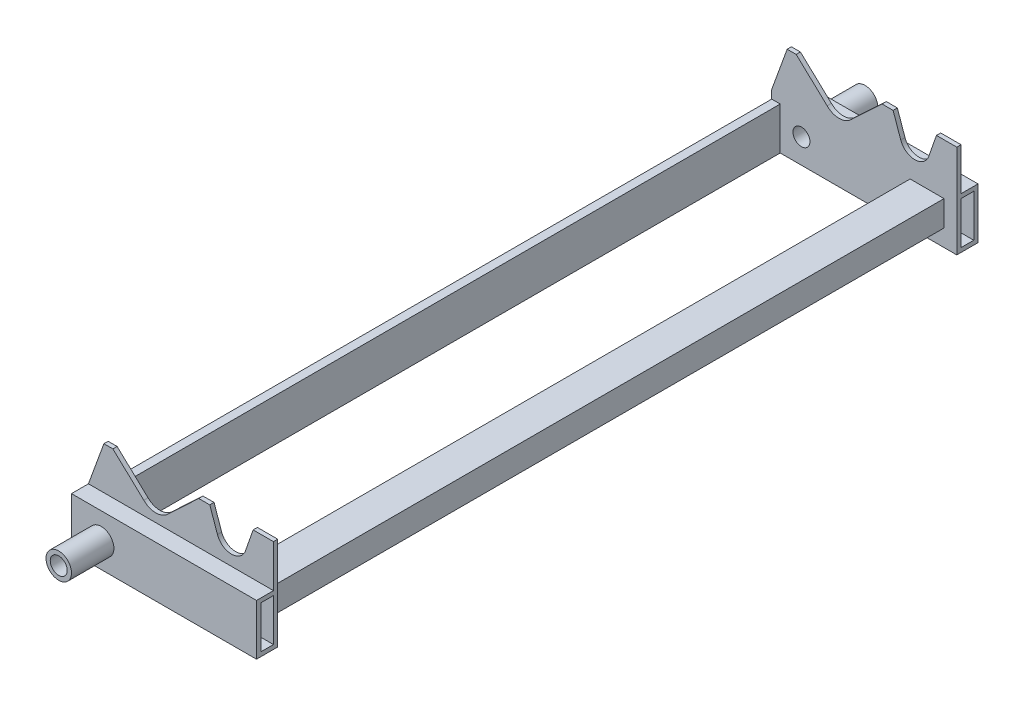
from build123d import *

# Parameters (mm, degrees)
SKETCH3_R           = 15
BOSS_EXTRUDE1_DEPTH = 25
SKETCH5_W           = 218
SKETCH5_H           = 50
CUT_EXTRUDE1_DEPTH  = 20
SKETCH7_W           = 15
SKETCH7_H           = 50
CUT_EXTRUDE3_DEPTH  = 219
SKETCH8_R           = 15
SKETCH8_R_2         = 10
BOSS_EXTRUDE7_DEPTH = 75
SKETCH9_W           = 10
SKETCH9_H           = 50
BOSS_EXTRUDE8_DEPTH = 400
SKETCH10_W          = 40
SKETCH10_H          = 30
SKETCH10_W_2        = 34
SKETCH10_H_2        = 24
BOSS_EXTRUDE9_DEPTH = 400


with BuildPart() as part:
    # Sketch3 → Boss-Extrude1 (new body)
    with BuildSketch(Plane.XY):
        with BuildLine():
            Line((-68.346942832, 96), (-86.545454545, 46))
            Line((-86.545454545, 46), (-86.545454545, -14))
            Line((-86.545454545, -14), (131.454545455, -14))
            Line((131.454545455, -14), (131.454545455, 96))
            Line((131.454545455, 96), (107.496522982, 96))
            Line((107.496522982, 96), (98.489850442, 70.226827292))
            ThreePointArc((98.489850442, 70.226827292), (81.969545455, 58.5), (65.449240467, 70.226827292))
            Line((65.449240467, 70.226827292), (56.442567927, 96))
            Line((56.442567927, 96), (43.395745829, 96))
            Line((43.395745829, 96), (6.961681078, 61.857864376))
            ThreePointArc((6.961681078, 61.857864376), (-7.180454545, 56), (-21.322590169, 61.857864376))
            Line((-21.322590169, 61.857864376), (-57.753891674, 96))
            Line((-57.753891674, 96), (-68.346942832, 96))
        make_face()
        with Locations((-51.545454545, 15)):
            Circle(SKETCH3_R, mode=Mode.SUBTRACT)
    extrude(amount=BOSS_EXTRUDE1_DEPTH)

    # Sketch5 → Cut-Extrude1 (cut)
    with BuildSketch(Plane.XY.offset(25)):
        with Locations((22.454545455, 71)):
            Rectangle(SKETCH5_W, SKETCH5_H)
    extrude(amount=-CUT_EXTRUDE1_DEPTH, mode=Mode.SUBTRACT)

    # Sketch7 → Cut-Extrude3 (cut, through all)
    with BuildSketch(Plane.ZY.offset(86.545454545)):
        with Locations((12.5, 16)):
            Rectangle(SKETCH7_W, SKETCH7_H)
    extrude(amount=-CUT_EXTRUDE3_DEPTH, mode=Mode.SUBTRACT)

    # Sketch8 → Boss-Extrude7 (add)
    with BuildSketch(Plane(origin=(0, 0, 0), x_dir=(-1, 0, 0), z_dir=(0, 0, -1))):
        with Locations((51.545454545, 15)):
            Circle(SKETCH8_R)
        with Locations((51.545454545, 15)):
            Circle(SKETCH8_R_2, mode=Mode.SUBTRACT)
    extrude(amount=-BOSS_EXTRUDE7_DEPTH)

    # Sketch9 → Boss-Extrude8 (add)
    with BuildSketch(Plane(origin=(0, 0, 0), x_dir=(-1, 0, 0), z_dir=(0, 0, -1))):
        with Locations((81.545454545, 11)):
            Rectangle(SKETCH9_W, SKETCH9_H)
    extrude(amount=BOSS_EXTRUDE8_DEPTH)

    # Sketch10 → Boss-Extrude9 (add)
    with BuildSketch(Plane(origin=(0, 0, 0), x_dir=(-1, 0, 0), z_dir=(0, 0, -1))):
        with Locations((-96.454545455, 21)):
            Rectangle(SKETCH10_W, SKETCH10_H)
        with Locations((-96.454545455, 21)):
            Rectangle(SKETCH10_W_2, SKETCH10_H_2, mode=Mode.SUBTRACT)
    extrude(amount=BOSS_EXTRUDE9_DEPTH)

    # Mirror1: part across plane


with BuildPart() as part_1:
    add(part.part)
    add(part.part.mirror(Plane(origin=(0, 0, -400), x_dir=(1, 0, 0), z_dir=(0, 0, -1))))


solid = part_1.part
